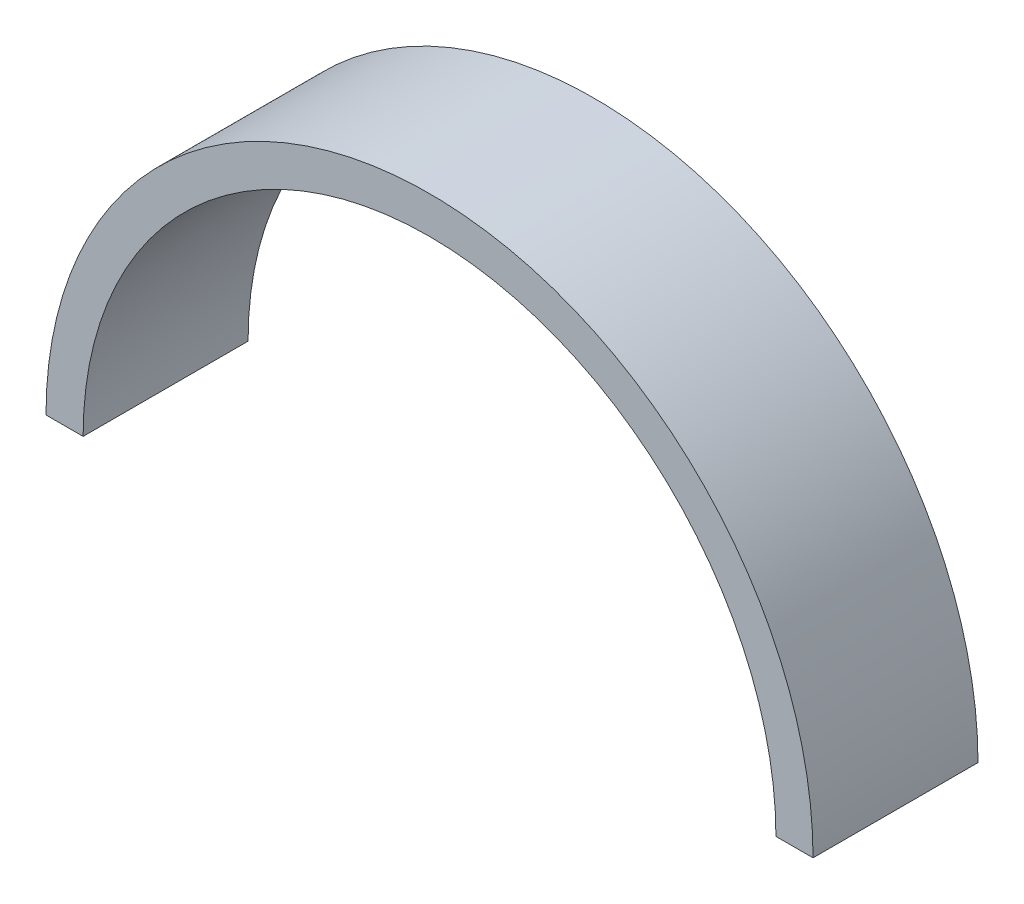
from build123d import *

# Parameters (mm, degrees)
EXTRUDE_1_DEPTH = 20


with BuildPart() as part:
    # 草图1 → 凸台-拉伸1 (new body)
    with BuildSketch(Plane.XY):
        with BuildLine():
            Line((-46.5, 0), (-42, 0))
            ThreePointArc((-42, 0), (0, 42), (42, 0))
            Line((42, 0), (46.5, 0))
            ThreePointArc((46.5, 0), (0, 46.5), (-46.5, 0))
        make_face()
    extrude(amount=EXTRUDE_1_DEPTH)


solid = part.part
